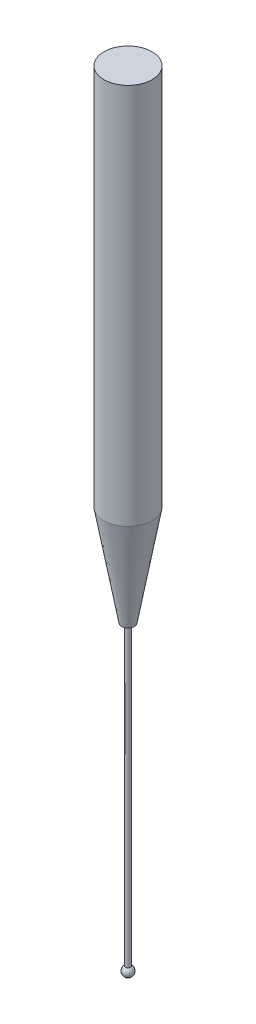
from build123d import *


with BuildPart() as part:
    # Sketch1 → Revolve1 (revolve)
    with BuildSketch(Plane.XY):
        with BuildLine():
            Line((0, 0), (2.4, 0))
            Line((2.4, 0), (2.4, -38))
            Line((2.4, -38), (0.636730193, -48))
            Line((0.636730193, -48), (0.250425685, -48))
            Line((0.250425685, -48), (0.250425685, -77.567233346))
            ThreePointArc((0.250425685, -77.567233346), (0.482899227, -78.129646969), (0, -78.5))
            Line((0, -78.5), (0, 0))
        make_face()
    revolve(axis=Axis((0, -156.170349764, 0), (0, 1, 0)))


solid = part.part
